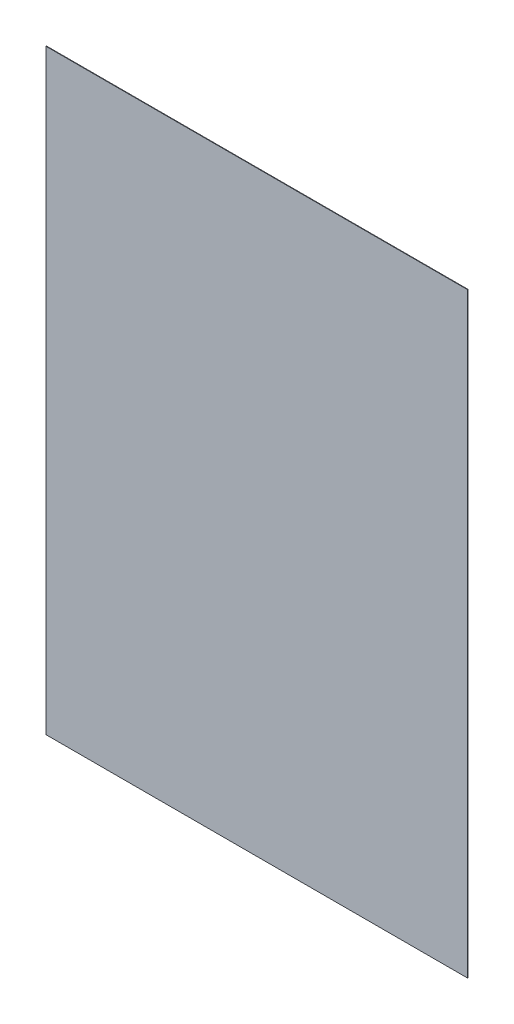
from build123d import *

# Parameters (mm, degrees)
SKETCH1_W           = 210.058
SKETCH1_H           = 297.18
BOSS_EXTRUDE1_DEPTH = 0.254


with BuildPart() as part:
    # Sketch1 → Boss-Extrude1 (new body)
    with BuildSketch(Plane.XY):
        with Locations((105.029, 148.59)):
            Rectangle(SKETCH1_W, SKETCH1_H)
    extrude(amount=BOSS_EXTRUDE1_DEPTH)


solid = part.part
